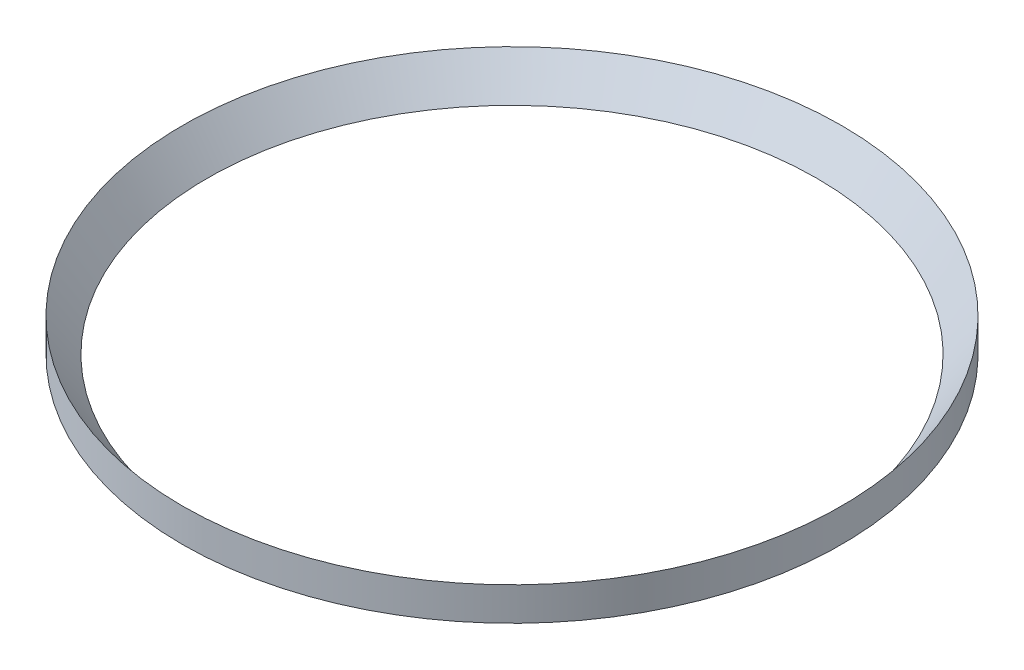
from build123d import *


with BuildPart() as part:
    # Sketch1 → Revolve1 (revolve)
    with BuildSketch(Plane.XY):
        Polygon((-16, 0), (-16, 1.62), (-14.8, 0), align=None)
    revolve(axis=Axis((0, 0, 0), (0, 1, 0)))


solid = part.part
